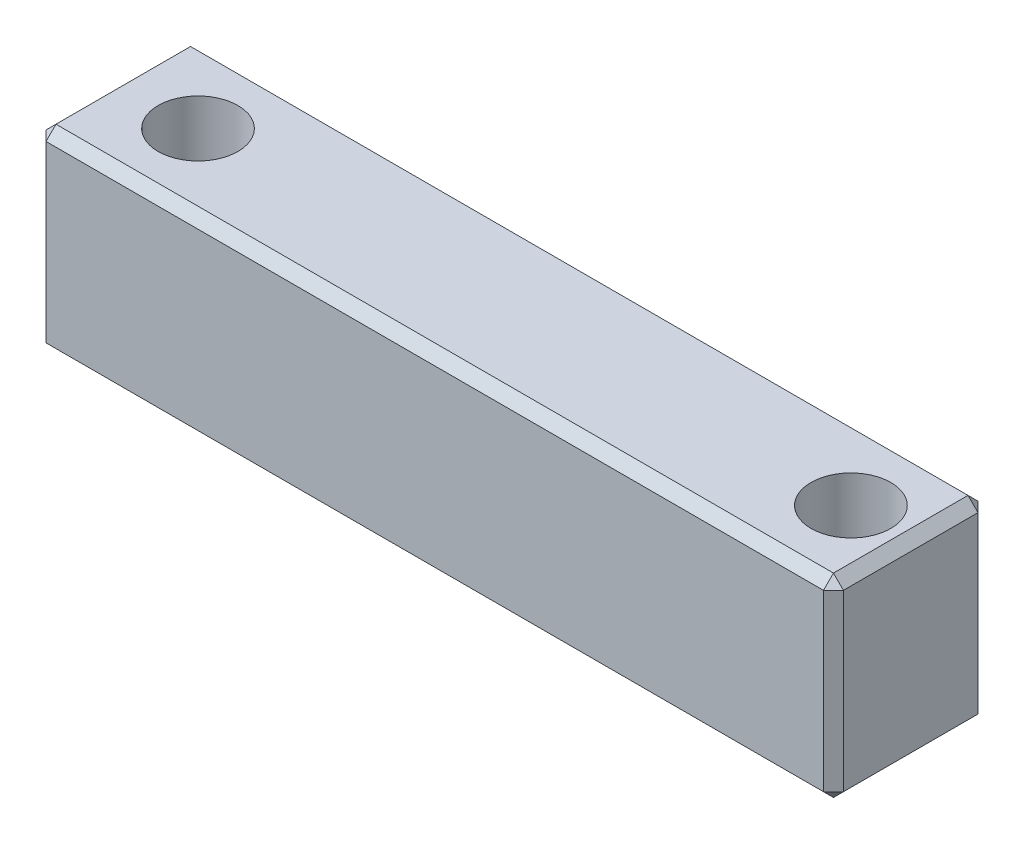
from build123d import *

# Parameters (mm, degrees)
SKETCH1_W           = 7.75
SKETCH1_H           = 9.75
BOSS_EXTRUDE1_DEPTH = 40
SKETCH4_R           = 2
CUT_EXTRUDE3_DEPTH  = 9.75
CHAMFER1_SIZE       = 0.5


with BuildPart() as part:
    # Sketch1 → Boss-Extrude1 (new body)
    with BuildSketch(Plane(origin=(0, 0, 0), x_dir=(0, 0, -1), z_dir=(1, 0, 0))):
        with Locations((3.875, 4.875)):
            Rectangle(SKETCH1_W, SKETCH1_H)
    extrude(amount=BOSS_EXTRUDE1_DEPTH)

    # Sketch4 → Cut-Extrude3 (cut)
    with BuildSketch(Plane(origin=(0, 9.75, 0), x_dir=(1, 0, 0), z_dir=(0, 1, 0))):
        with Locations((4.25, 3.875)):
            Circle(SKETCH4_R)
        with Locations((37, 3.875)):
            Circle(SKETCH4_R)
    extrude(amount=-CUT_EXTRUDE3_DEPTH, mode=Mode.SUBTRACT)

    # Chamfer1
    chamfer1_edges = [part.edges().sort_by_distance(p)[0] for p in [
        (40, 4.875, -7.75),
        (40, 9.75, -3.875),
        (40, 4.875, 0),
        (0, 9.75, -3.875),
        (0, 4.875, -7.75),
        (0, 0, -3.875),
        (0, 4.875, 0),
        (20, 9.75, 0),
        (20, 9.75, -7.75),
        (20, 0, -7.75),
        (20, 0, 0),
        (40, 0, -3.875),
    ]]
    chamfer(chamfer1_edges, length=CHAMFER1_SIZE)


solid = part.part
